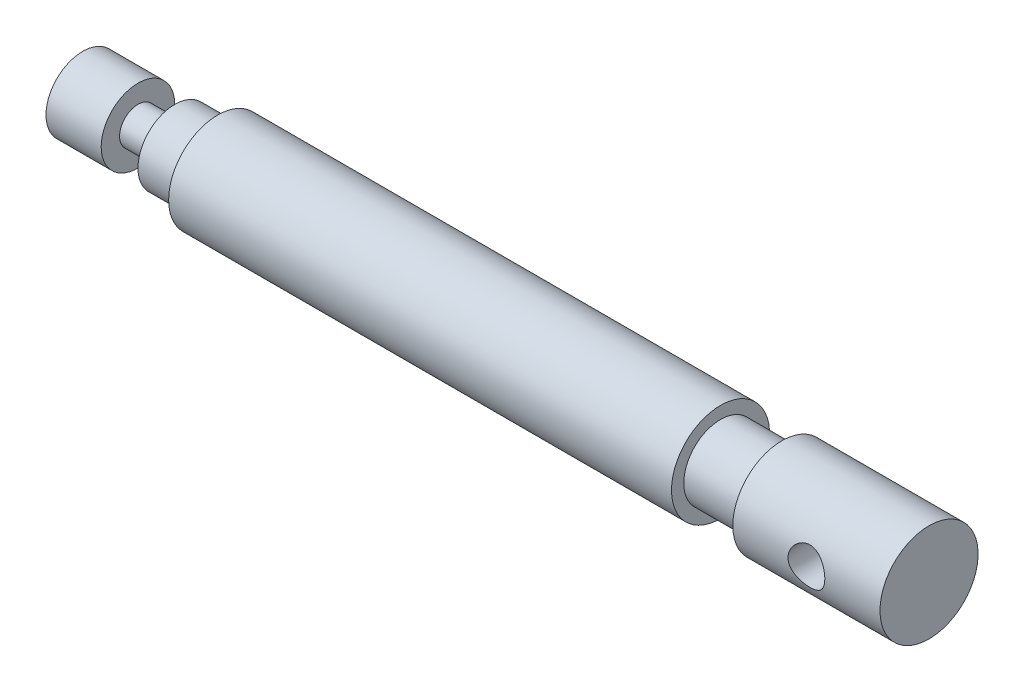
from build123d import *

# Parameters (mm, degrees)
SKETCH2_R               = 3
CUT_EXTRUDE1_DEPTH      = 9
CUT_EXTRUDE1_DEPTH_BACK = 9


with BuildPart() as part:
    # Sketch1 → Revolve1 (revolve)
    with BuildSketch(Plane.XY):
        Polygon((0, 0), (0, 6), (9, 6), (9, 3), (15, 3), (15, 6), (22, 6), (22, 8), (104, 8), (104, 6), (114, 6), (114, 8), (138, 8), (138, 0), align=None)
    revolve(axis=Axis((0, 0, 0), (1, 0, 0)))

    # Sketch2 → Cut-Extrude1 (cut, two sides)
    with BuildSketch(Plane.XY) as cut_extrude1_sk:
        with Locations((126, 0)):
            Circle(SKETCH2_R)
    extrude(amount=CUT_EXTRUDE1_DEPTH, mode=Mode.SUBTRACT)
    extrude(cut_extrude1_sk.sketch, amount=-CUT_EXTRUDE1_DEPTH_BACK, mode=Mode.SUBTRACT)


solid = part.part
